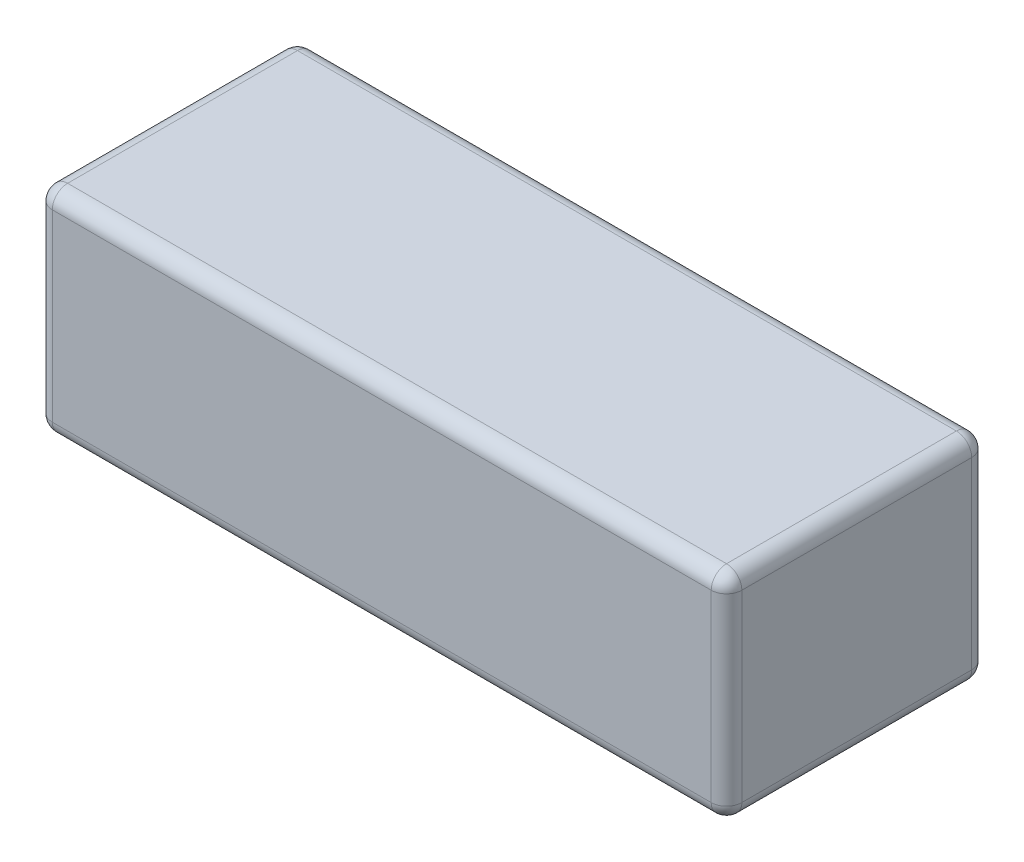
from build123d import *

# Parameters (mm, degrees)
SKETCH1_W           = 90
SKETCH1_H           = 34
BOSS_EXTRUDE1_DEPTH = 28
FILLET1_R           = 2


with BuildPart() as part:
    # Sketch1 → Boss-Extrude1 (new body)
    with BuildSketch(Plane(origin=(0, 0, 0), x_dir=(1, 0, 0), z_dir=(0, 1, 0))):
        Rectangle(SKETCH1_W, SKETCH1_H)
    extrude(amount=BOSS_EXTRUDE1_DEPTH)

    # Fillet1
    fillet1_edges = [part.edges().sort_by_distance(p)[0] for p in [
        (-45, 28, 0),
        (0, 28, 17),
        (45, 28, 0),
        (0, 0, 17),
        (-45, 0, 0),
        (0, 0, -17),
        (45, 0, 0),
        (45, 14, 17),
        (-45, 14, 17),
        (-45, 14, -17),
        (45, 14, -17),
        (0, 28, -17),
    ]]
    fillet(fillet1_edges, radius=FILLET1_R)


solid = part.part
